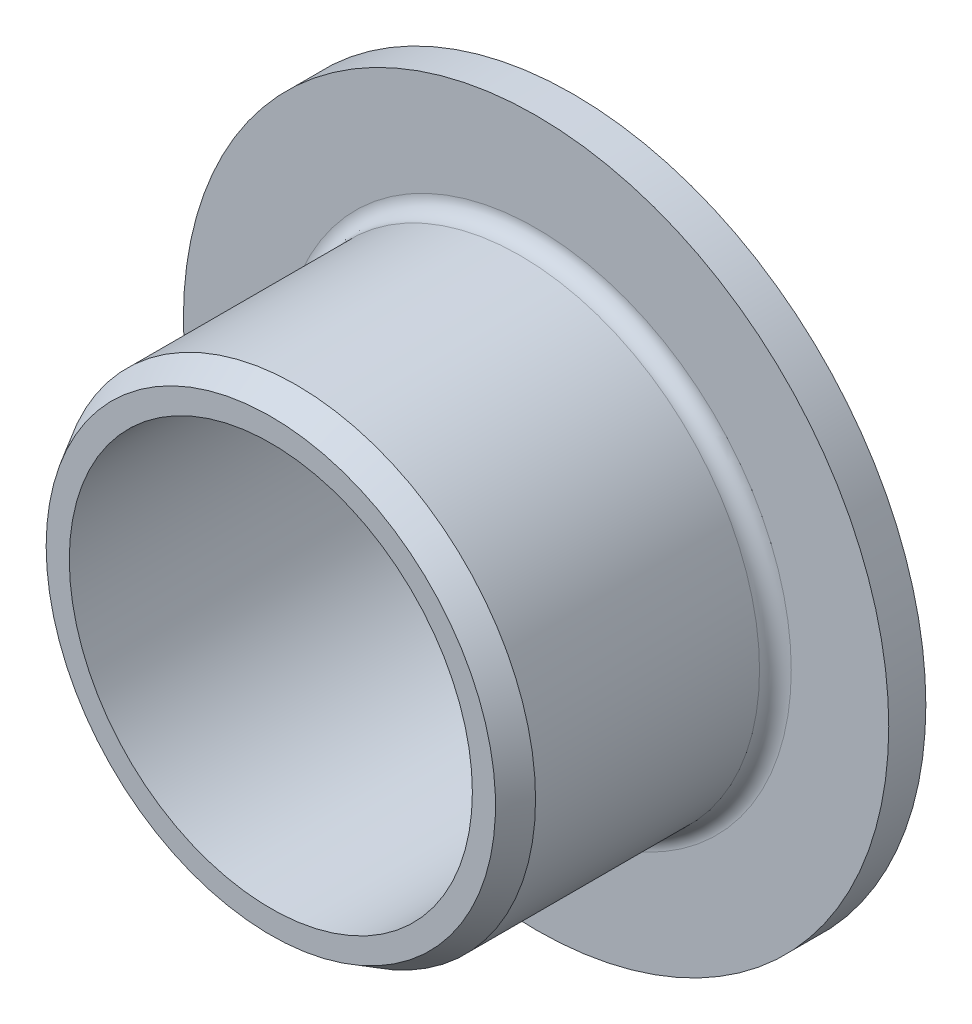
from build123d import *


with BuildPart() as part:
    # Sketch1 → Revolve1 (revolve)
    with BuildSketch(Plane.XZ):
        with BuildLine():
            Line((7.540625, 1.6684), (7.540625, 8.725))
            Line((7.540625, 8.725), (7.078744785, 9.525))
            Line((7.078744785, 9.525), (6.35, 9.525))
            Line((6.35, 9.525), (6.35, 0))
            Line((6.35, 0), (11.1125, 0))
            Line((11.1125, 0), (11.1125, 1.1684))
            Line((11.1125, 1.1684), (8.040625, 1.1684))
            ThreePointArc((8.040625, 1.1684), (7.687071609, 1.314846609), (7.540625, 1.6684))
        make_face()
    revolve(axis=Axis((0, 0, 9.525), (0, 0, -1)))


solid = part.part
